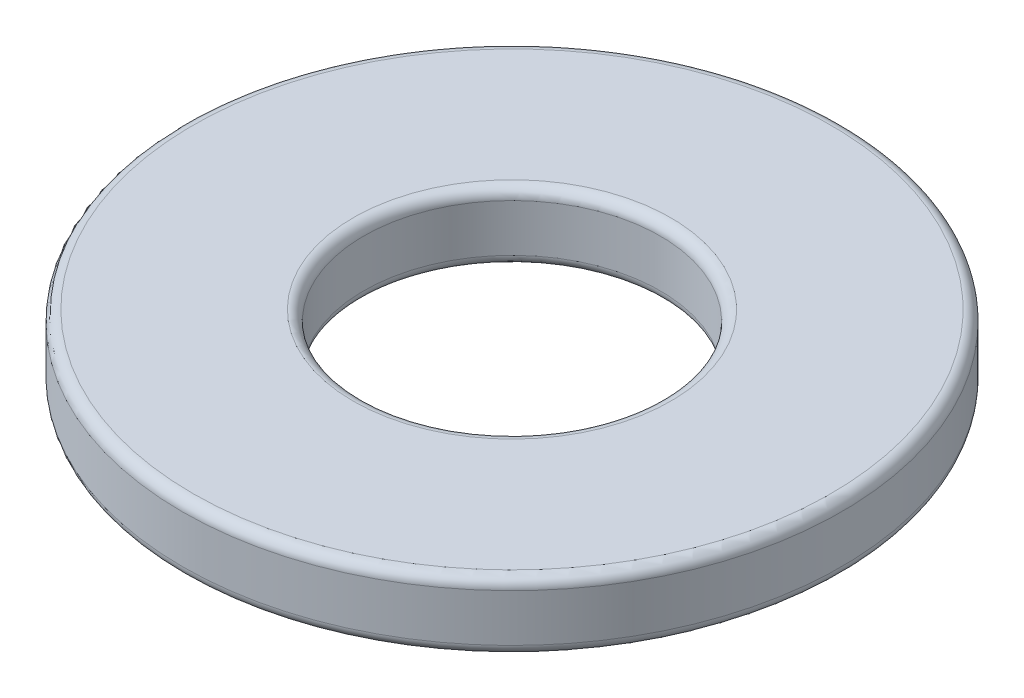
from build123d import *

# Parameters (mm, degrees)
SKETCH1_R      = 7.9375
SKETCH1_R_2    = 3.571875
EXTRUDE1_DEPTH = 1.651
FILLET1_R      = 0.254


with BuildPart() as part:
    # Sketch1 → Extrude1 (new body)
    with BuildSketch(Plane(origin=(0, 0, 0), x_dir=(1, 0, 0), z_dir=(0, 1, 0))):
        with Locations(Location((0, 0, 0), (0, 0, 270))):  # turned: the seam where the file's is
            Circle(SKETCH1_R)
        with Locations(Location((0, 0, 0), (0, 0, 270))):  # turned: the seam where the file's is
            Circle(SKETCH1_R_2, mode=Mode.SUBTRACT)
    extrude(amount=EXTRUDE1_DEPTH)

    # Fillet1
    fillet1_edges = [part.edges().sort_by_distance(p)[0] for p in [
        (0, 0, -7.9375),
        (0, 1.651, -7.9375),
        (0, 0, -3.571875),
        (0, 1.651, -3.571875),
    ]]
    fillet(fillet1_edges, radius=FILLET1_R)


solid = part.part
